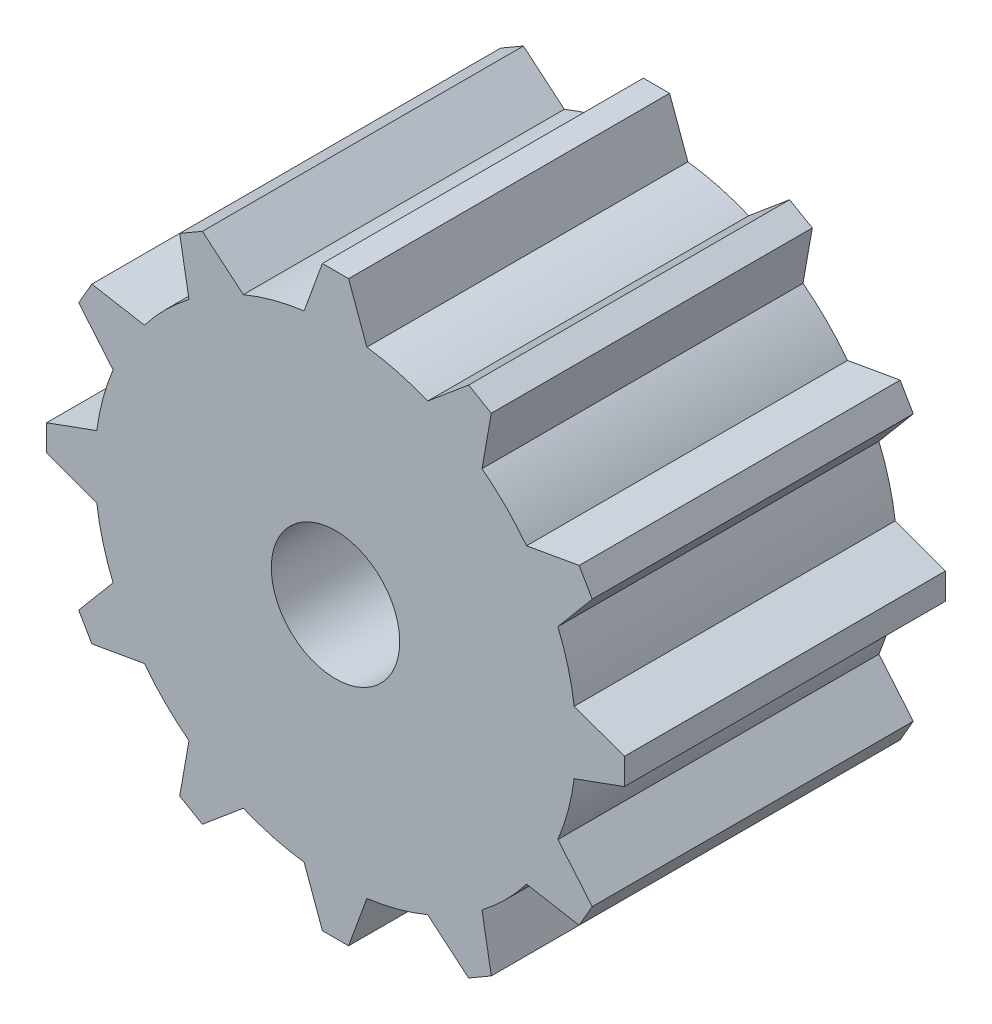
from build123d import *

# Parameters (mm, degrees)
IZIM1_R                     = 7.5
Y_KSEKLIK_EKSTR_ZYON1_DEPTH = 5
Y_KSEKLIK_EKSTR_ZYON2_DEPTH = 5
IZIM3_R                     = 2
KES_EKSTR_ZYON1_DEPTH       = 11


with BuildPart() as part:
    # Çizim1 → Yükseklik-Ekstrüzyon1 (new body, symmetric)
    with BuildSketch(Plane.XY):
        Circle(IZIM1_R)
    extrude(amount=Y_KSEKLIK_EKSTR_ZYON1_DEPTH, both=True)

    # Çizim2 → Yükseklik-Ekstrüzyon2 (add, symmetric)
    with BuildSketch(Plane.XY):
        Polygon((-1.5, 6), (1.5, 6), (0.408089297, 9), (-0.408089297, 9), align=None)
        Polygon((4.146584302, 7.998273283), (1.700961894, 5.946152423), (4.299038106, 4.446152423), (4.853415698, 7.590183985), align=None)
        Polygon((7.590183985, 4.853415698), (4.446152423, 4.299038106), (5.946152423, 1.700961894), (7.998273283, 4.146584302), align=None)
        Polygon((9, 0.408089297), (6, 1.5), (6, -1.5), (9, -0.408089297), align=None)
        Polygon((7.998273283, -4.146584302), (5.946152423, -1.700961894), (4.446152423, -4.299038106), (7.590183985, -4.853415698), align=None)
        Polygon((4.853415698, -7.590183985), (4.299038106, -4.446152423), (1.700961894, -5.946152423), (4.146584302, -7.998273283), align=None)
        Polygon((0.408089297, -9), (1.5, -6), (-1.5, -6), (-0.408089297, -9), align=None)
        Polygon((-4.146584302, -7.998273283), (-1.700961894, -5.946152423), (-4.299038106, -4.446152423), (-4.853415698, -7.590183985), align=None)
        Polygon((-7.590183985, -4.853415698), (-4.446152423, -4.299038106), (-5.946152423, -1.700961894), (-7.998273283, -4.146584302), align=None)
        Polygon((-9, -0.408089297), (-6, -1.5), (-6, 1.5), (-9, 0.408089297), align=None)
        Polygon((-7.998273283, 4.146584302), (-5.946152423, 1.700961894), (-4.446152423, 4.299038106), (-7.590183985, 4.853415698), align=None)
        Polygon((-4.853415698, 7.590183985), (-4.299038106, 4.446152423), (-1.700961894, 5.946152423), (-4.146584302, 7.998273283), align=None)
    extrude(amount=Y_KSEKLIK_EKSTR_ZYON2_DEPTH, both=True)

    # Çizim3 → Kes-Ekstrüzyon1 (cut, through all)
    with BuildSketch(Plane.XY.offset(5)):
        Circle(IZIM3_R)
    extrude(amount=-KES_EKSTR_ZYON1_DEPTH, mode=Mode.SUBTRACT)


solid = part.part
